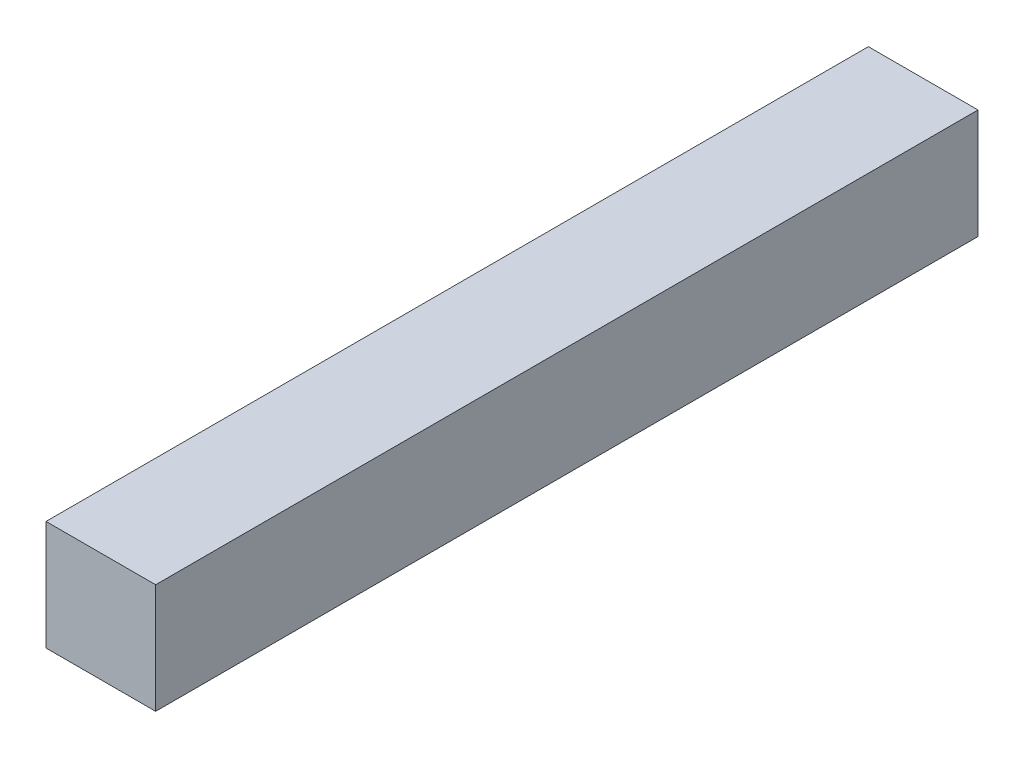
from build123d import *

# Parameters (mm, degrees)
SKETCH7_W           = 20.32
SKETCH7_H           = 20.32
BOSS_EXTRUDE3_DEPTH = 76.2


with BuildPart() as part:
    # Sketch7 → Boss-Extrude3 (new body, symmetric)
    with BuildSketch(Plane.XY):
        Rectangle(SKETCH7_W, SKETCH7_H)
    extrude(amount=BOSS_EXTRUDE3_DEPTH, both=True)


solid = part.part
